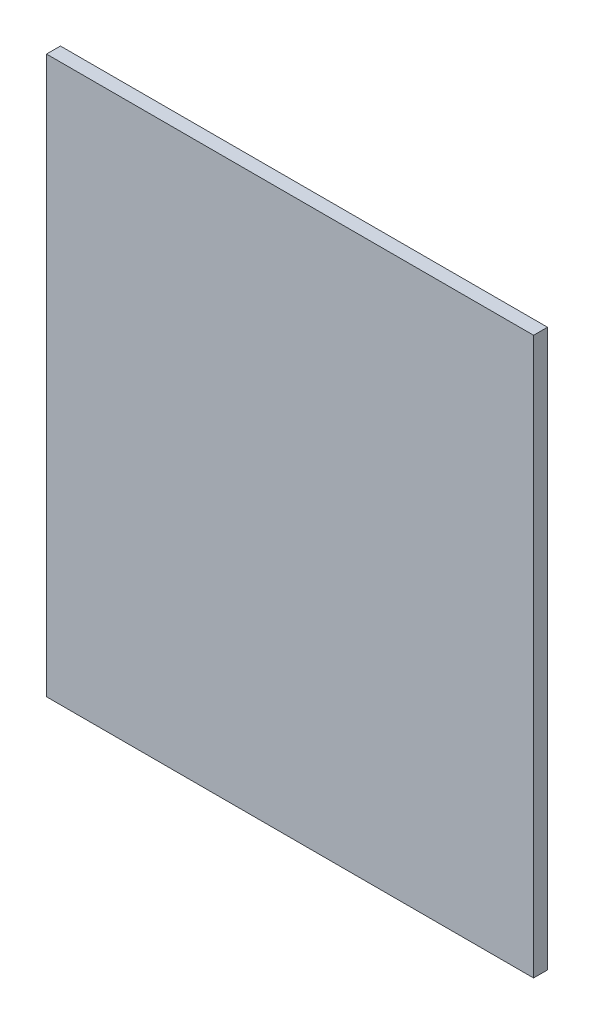
from build123d import *

# Parameters (mm, degrees)
SKETCH1_W           = 101.6
SKETCH1_H           = 88.9
BOSS_EXTRUDE1_DEPTH = 2.54


with BuildPart() as part:
    # Sketch1 → Boss-Extrude1 (new body)
    with BuildSketch(Plane(origin=(0, 0, 0), x_dir=(0, 1, 0), z_dir=(0, 0, 1))):
        with Locations((50.8, 44.45)):
            Rectangle(SKETCH1_W, SKETCH1_H)
    extrude(amount=BOSS_EXTRUDE1_DEPTH)


solid = part.part
